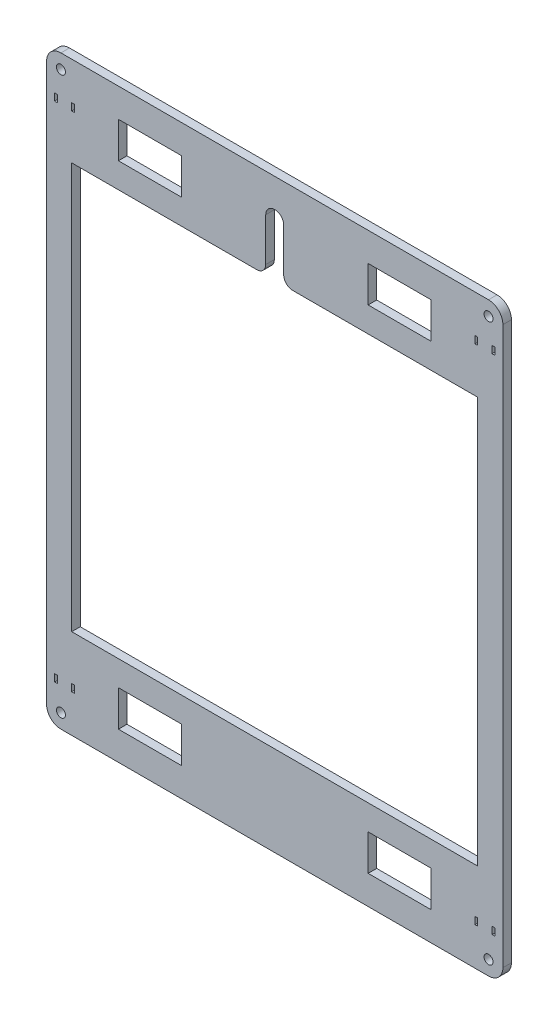
from build123d import *

# Parameters (mm, degrees)
BOSS_EXTRUDE1_DEPTH = 4.7625
SKETCH2_R           = 2.5
SKETCH2_W           = 35
SKETCH2_H           = 20
SKETCH2_W_2         = 1.5
SKETCH2_H_2         = 4
CUT_EXTRUDE1_DEPTH  = 10


with BuildPart() as part:
    # Sketch1 → Boss-Extrude1 (new body)
    with BuildSketch(Plane.XY):
        with BuildLine():
            Line((-66.942601108, 67.806403557), (-66.942601108, -242.193596443))
            ThreePointArc((-66.942601108, -242.193596443), (-64.599455358, -247.850450692), (-58.942601108, -250.193596443))
            Line((-58.942601108, -250.193596443), (179.057398892, -250.193596443))
            ThreePointArc((179.057398892, -250.193596443), (184.714253141, -247.850450692), (187.057398892, -242.193596443))
            Line((187.057398892, -242.193596443), (187.057398892, 67.806403557))
            ThreePointArc((187.057398892, 67.806403557), (184.714253141, 73.463257807), (179.057398892, 75.806403557))
            Line((179.057398892, 75.806403557), (-58.942601108, 75.806403557))
            ThreePointArc((-58.942601108, 75.806403557), (-64.599455358, 73.463257807), (-66.942601108, 67.806403557))
        make_face()
    extrude(amount=-BOSS_EXTRUDE1_DEPTH)

    # Sketch2 → Cut-Extrude1 (cut)
    with BuildSketch(Plane.XY):
        with Locations((179.057398892, 67.806403557)):
            Circle(SKETCH2_R)
        with Locations((-58.942601108, 67.806403557)):
            Circle(SKETCH2_R)
        with Locations((-58.942601108, -242.193596443)):
            Circle(SKETCH2_R)
        with Locations((179.057398892, -242.193596443)):
            Circle(SKETCH2_R)
        with BuildLine():
            Line((173.057398892, 25.806403557), (70.057398892, 25.806403557))
            ThreePointArc((70.057398892, 25.806403557), (66.521864986, 27.270869651), (65.057398892, 30.806403557))
            Line((65.057398892, 30.806403557), (65.057398892, 54.806403557))
            ThreePointArc((65.057398892, 54.806403557), (60.057398892, 59.806403557), (55.057398892, 54.806403557))
            Line((55.057398892, 54.806403557), (55.057398892, 30.806403557))
            ThreePointArc((55.057398892, 30.806403557), (53.592932798, 27.270869651), (50.057398892, 25.806403557))
            Line((50.057398892, 25.806403557), (-52.942601108, 25.806403557))
            Line((-52.942601108, 25.806403557), (-52.942601108, -200.193596443))
            Line((-52.942601108, -200.193596443), (173.057398892, -200.193596443))
            Line((173.057398892, -200.193596443), (173.057398892, 25.806403557))
        make_face()
        with Locations((-9.442601108, 49.806403557)):
            Rectangle(SKETCH2_W, SKETCH2_H)
        with Locations((129.557398892, 49.806403557)):
            Rectangle(SKETCH2_W, SKETCH2_H)
        with Locations((-61.692601108, 52.806403557)):
            Rectangle(SKETCH2_W_2, SKETCH2_H_2)
        with Locations((-52.192601108, 52.806403557)):
            Rectangle(SKETCH2_W_2, SKETCH2_H_2)
        with Locations((172.307398892, 52.806403557)):
            Rectangle(SKETCH2_W_2, SKETCH2_H_2)
        with Locations((181.807398892, 52.806403557)):
            Rectangle(SKETCH2_W_2, SKETCH2_H_2)
        with Locations((-9.442601108, -224.193596443)):
            Rectangle(SKETCH2_W, SKETCH2_H)
        with Locations((-61.692601108, -227.193596443)):
            Rectangle(SKETCH2_W_2, SKETCH2_H_2)
        with Locations((-52.192601108, -227.193596443)):
            Rectangle(SKETCH2_W_2, SKETCH2_H_2)
        with Locations((181.807398892, -227.193596443)):
            Rectangle(SKETCH2_W_2, SKETCH2_H_2)
        with Locations((172.307398892, -227.193596443)):
            Rectangle(SKETCH2_W_2, SKETCH2_H_2)
        with Locations((129.557398892, -224.193596443)):
            Rectangle(SKETCH2_W, SKETCH2_H)
    extrude(amount=-CUT_EXTRUDE1_DEPTH, mode=Mode.SUBTRACT)


solid = part.part
